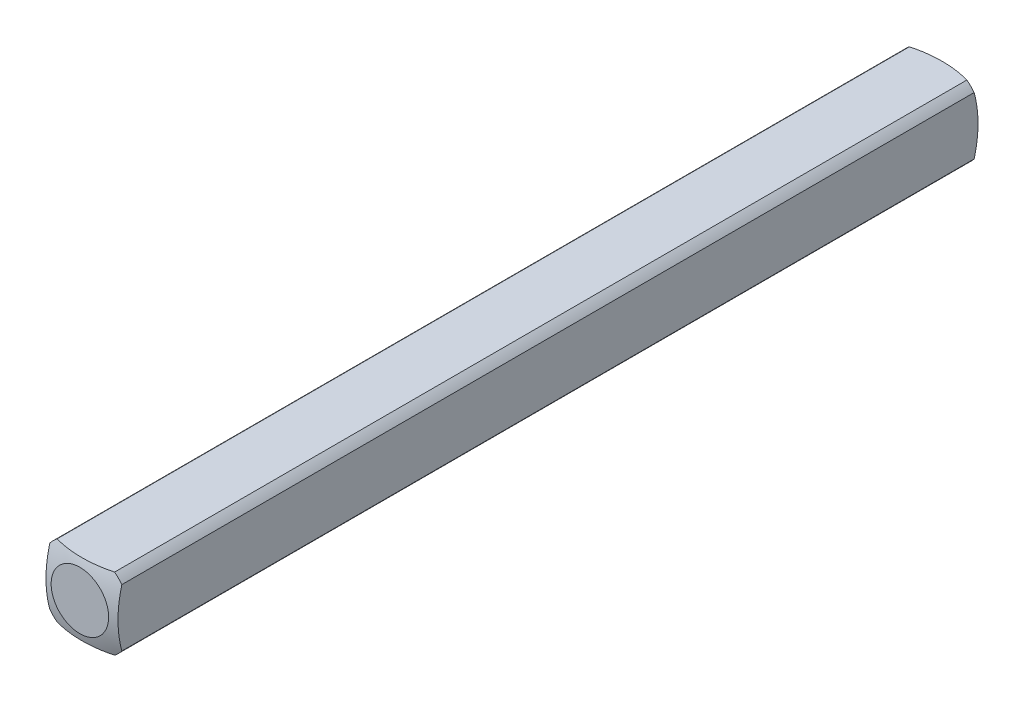
from build123d import *

# Parameters (mm, degrees)
SKETCH1_W           = 3.175
SKETCH1_H           = 3.175
BOSS_EXTRUDE1_DEPTH = 19.05
SKETCH2_OUTSIDE_W   = 9.088
SKETCH2_OUTSIDE_H   = 9.089
SKETCH2_OUTSIDE_R   = 2.032
CUT_EXTRUDE1_DEPTH  = 20.05


with BuildPart() as part:
    # Sketch1 → Boss-Extrude1 (new body)
    with BuildSketch(Plane.XY):
        Rectangle(SKETCH1_W, SKETCH1_H)
    extrude(amount=BOSS_EXTRUDE1_DEPTH)

    # Sketch2 outside → Cut-Extrude1 (cut, through all)
    with BuildSketch(Plane(origin=(0, 0, 0), x_dir=(-1, 0, 0), z_dir=(0, 0, -1))):
        with Locations((0, -0.0005)):
            Rectangle(SKETCH2_OUTSIDE_W, SKETCH2_OUTSIDE_H)
        Circle(SKETCH2_OUTSIDE_R, mode=Mode.SUBTRACT)
    extrude(amount=-CUT_EXTRUDE1_DEPTH, mode=Mode.SUBTRACT)

    # Sketch3 → Cut-Revolve1 (revolve, cut)
    with BuildSketch(Plane(origin=(0, 0, 0), x_dir=(1, 0, 0), z_dir=(0, 1, 0))):
        with BuildLine():
            Line((-5.053685963, -4.40273269), (-5.053685963, 5.740530545))
            Line((-5.053685963, 5.740530545), (0, 5.740530545))
            Line((0, 5.740530545), (0, 0.160877736))
            ThreePointArc((0, 0.160877736), (-3.404639553, -1.148866368), (-5.053685963, -4.40273269))
        make_face()
    revolve(axis=Axis((0, 0, 19.05), (0, 0, -1)), mode=Mode.SUBTRACT)

    # Mirror1: part across plane


with BuildPart() as part_1:
    add(part.part)
    add(part.part.mirror(Plane(origin=(0, 0, 19.05), x_dir=(1, 0, 0), z_dir=(0, 0, -1))))


solid = part_1.part
